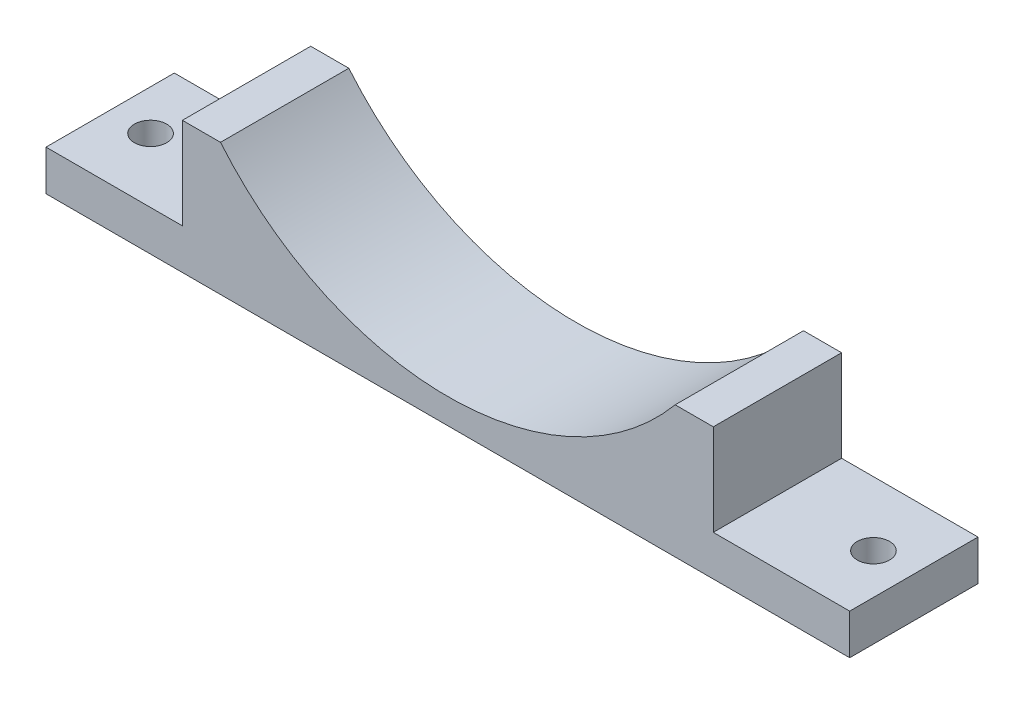
from build123d import *

# Parameters (mm, degrees)
BOSS_EXTRUDE1_DEPTH = 25.4
SKETCH2_R           = 3.2
CUT_EXTRUDE1_DEPTH  = 9


with BuildPart() as part:
    # Sketch1 → Boss-Extrude1 (new body)
    with BuildSketch(Plane.XY):
        with BuildLine():
            Line((124.545, 26.094806075), (132.09, 26.094806075))
            Line((132.09, 26.094806075), (132.09, 8))
            Line((132.09, 8), (159.09, 8))
            Line((159.09, 8), (159.09, 0))
            Line((159.09, 0), (0, 0))
            Line((0, 0), (0, 8))
            Line((0, 8), (27, 8))
            Line((27, 8), (27, 26.094806075))
            Line((27, 26.094806075), (34.545, 26.094806075))
            ThreePointArc((34.545, 26.094806075), (79.545, 5), (124.545, 26.094806075))
        make_face()
    extrude(amount=BOSS_EXTRUDE1_DEPTH)

    # Sketch2 → Cut-Extrude1 (cut, through all)
    with BuildSketch(Plane(origin=(0, 8, 0), x_dir=(1, 0, 0), z_dir=(0, 1, 0))):
        with Locations((8, -12.7)):
            Circle(SKETCH2_R)
        with Locations((151.09, -12.7)):
            Circle(SKETCH2_R)
    extrude(amount=-CUT_EXTRUDE1_DEPTH, mode=Mode.SUBTRACT)


solid = part.part
